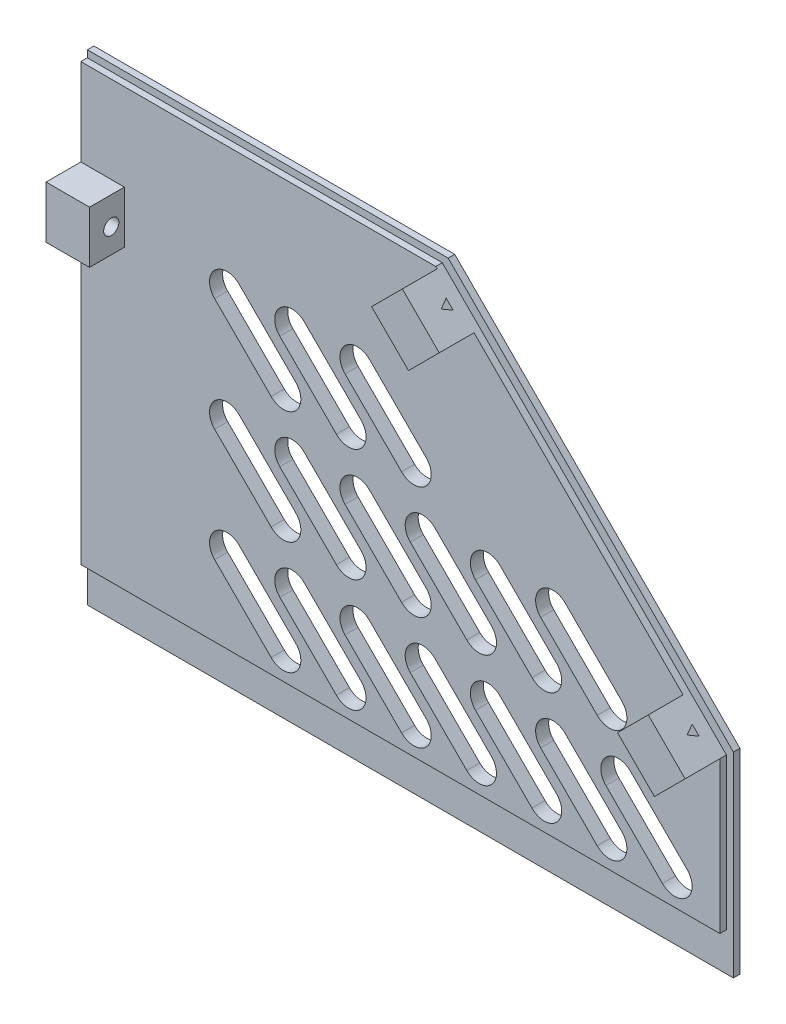
from build123d import *

# Parameters (mm, degrees)
SALIENTE_EXTRUIR1_DEPTH = 1.5
SALIENTE_EXTRUIR2_DEPTH = 1.5
VENTILACION_DEPTH       = 3
MATRIZL1_COUNT          = 7
MATRIZL1_PITCH          = 15
MATRIZL1_COUNT_DIR2     = 3
MATRIZL1_PITCH_DIR2     = 26
CROQUIS4_W              = 10
CROQUIS4_H              = 12
SALIENTE_EXTRUIR3_DEPTH = 8
FIX_SUP_REACH           = 150.6
CROQUIS5_R              = 1.75
SALIENTE_EXTRUIR4_DEPTH = 8
CORTAR_EXTRUIR4_DEPTH   = 10
MATRIZL2_COUNT          = 2
MATRIZL2_PITCH          = 80


with BuildPart() as part:
    # Croquis1 → Saliente-Extruir1 (new body)
    with BuildSketch(Plane.XY):
        Polygon((74.3, 0), (-74.3, 0), (-74.3, 110.6), (8.7, 110.6), (74.3, 45), align=None)
    extrude(amount=SALIENTE_EXTRUIR1_DEPTH)

    # Croquis2 → Saliente-Extruir2 (add)
    with BuildSketch(Plane.XY.offset(1.5)):
        Polygon((-74.3, 109), (-74.3, 8.8), (72.7, 8.8), (72.7, 43.630151519), (7.330151519, 109), align=None)
    extrude(amount=SALIENTE_EXTRUIR2_DEPTH)

    # Croquis3 → ventilacion (cut)
    with BuildSketch(Plane.XY):
        with BuildLine():
            Line((52.128427125, 30.828427125), (65.128427125, 17.828427125))
            ThreePointArc((65.128427125, 17.828427125), (65.128427125, 12.171572875), (59.471572875, 12.171572875))
            Line((59.471572875, 12.171572875), (46.471572875, 25.171572875))
            ThreePointArc((46.471572875, 25.171572875), (46.471572875, 30.828427125), (52.128427125, 30.828427125))
        make_face()
    ventilacion = extrude(amount=VENTILACION_DEPTH, mode=Mode.SUBTRACT)

    # MatrizL1: ventilacion 7 × 3, 5 skipped
    with Locations(*[(-i * MATRIZL1_PITCH, j * MATRIZL1_PITCH_DIR2, 0) for i in range(MATRIZL1_COUNT) for j in range(MATRIZL1_COUNT_DIR2) if (i, j) not in ((0, 0), (0, 1), (0, 2), (1, 2), (2, 2), (3, 2))]):
        add(ventilacion, mode=Mode.SUBTRACT)

    # Croquis4 → Saliente-Extruir3 (add)
    with BuildSketch(Plane.XY.offset(3)):
        with Locations((-69.3, 83)):
            Rectangle(CROQUIS4_W, CROQUIS4_H)
    extrude(amount=SALIENTE_EXTRUIR3_DEPTH)

    # Croquis5 → fix-sup (cut, up to next)
    with BuildSketch(Plane.ZY.offset(74.3), mode=Mode.PRIVATE) as fix_sup_sk1:
        with Locations((6, 82.6)):
            Circle(CROQUIS5_R)
    fix_sup_tool1 = extrude(fix_sup_sk1.sketch, amount=-FIX_SUP_REACH, mode=Mode.PRIVATE) & part.part
    add(fix_sup_tool1.solids().sort_by_distance((-74.3, 82.6, 6))[0], mode=Mode.SUBTRACT)

    # Croquis6 → Saliente-Extruir4 (add)
    with BuildSketch(Plane.XY.offset(3)):
        Polygon((72.7, 43.630151519), (64.214718626, 52.115432893), (57.143650814, 45.044365081), (65.628932188, 36.559083707), align=None)
    saliente_extruir4 = extrude(amount=SALIENTE_EXTRUIR4_DEPTH)

    # Croquis7 → Cortar-Extruir4 (cut)
    with BuildSketch(Plane(origin=(58.16507576, 58.16507576, 0), x_dir=(0, 0, -1), z_dir=(0.707106781, 0.707106781, 0))):
        Polygon((-4.35, -13.429653964), (-6.3, -14.555486989), (-4.35, -15.681320014), align=None)
    cortar_extruir4 = extrude(amount=-CORTAR_EXTRUIR4_DEPTH, mode=Mode.SUBTRACT)

    # MatrizL2: Saliente-Extruir4, Cortar-Extruir4 ×2
    with Locations(*[Vector(-0.707106781, 0.707106781, 0) * (i * MATRIZL2_PITCH) for i in range(1, MATRIZL2_COUNT)]):
        add(saliente_extruir4)
        add(cortar_extruir4, mode=Mode.SUBTRACT)


solid = part.part
